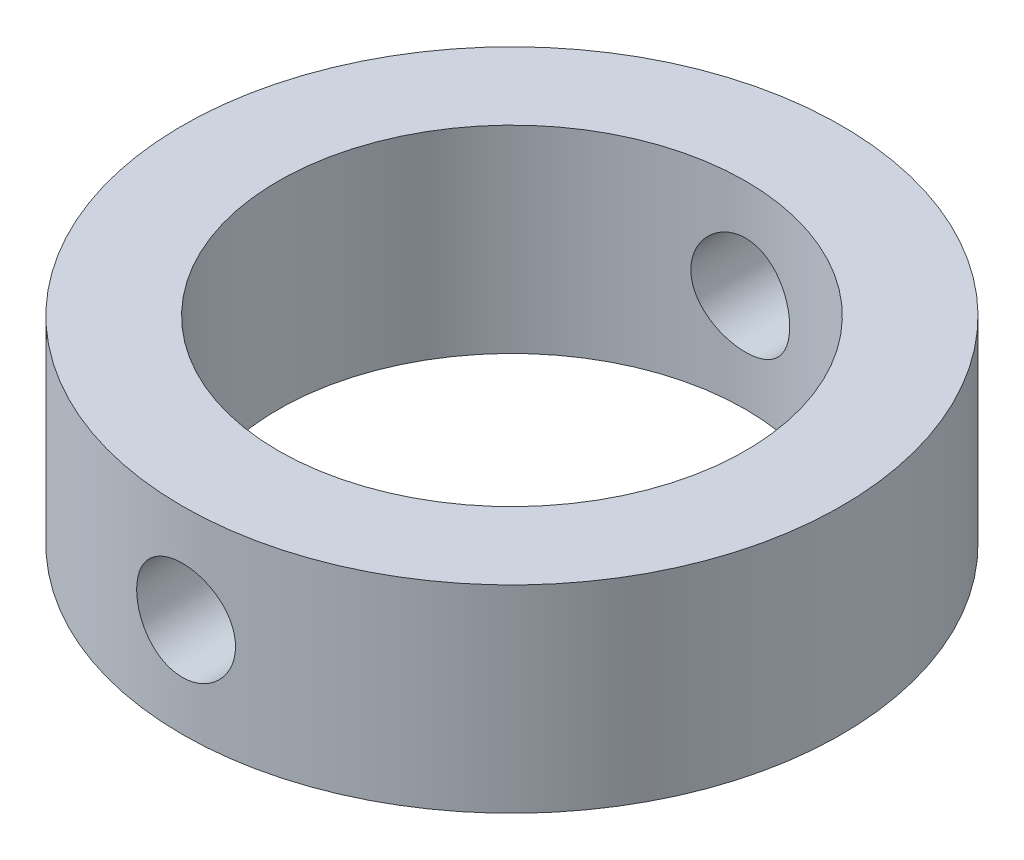
from build123d import *

# Parameters (mm, degrees)
SKETCH1_R               = 25
SKETCH1_R_2             = 17.7222
BOSS_EXTRUDE1_DEPTH     = 7.5
SKETCH2_R               = 3.75
CUT_EXTRUDE1_DEPTH      = 26
CUT_EXTRUDE1_DEPTH_BACK = 26


with BuildPart() as part:
    # Sketch1 → Boss-Extrude1 (new body, symmetric)
    with BuildSketch(Plane(origin=(0, 0, 0), x_dir=(1, 0, 0), z_dir=(0, 1, 0))):
        Circle(SKETCH1_R)
        Circle(SKETCH1_R_2, mode=Mode.SUBTRACT)
    extrude(amount=BOSS_EXTRUDE1_DEPTH, both=True)

    # Sketch2 → Cut-Extrude1 (cut, two sides)
    with BuildSketch(Plane.XY) as cut_extrude1_sk:
        Circle(SKETCH2_R)
    extrude(amount=CUT_EXTRUDE1_DEPTH, mode=Mode.SUBTRACT)
    extrude(cut_extrude1_sk.sketch, amount=-CUT_EXTRUDE1_DEPTH_BACK, mode=Mode.SUBTRACT)


solid = part.part
